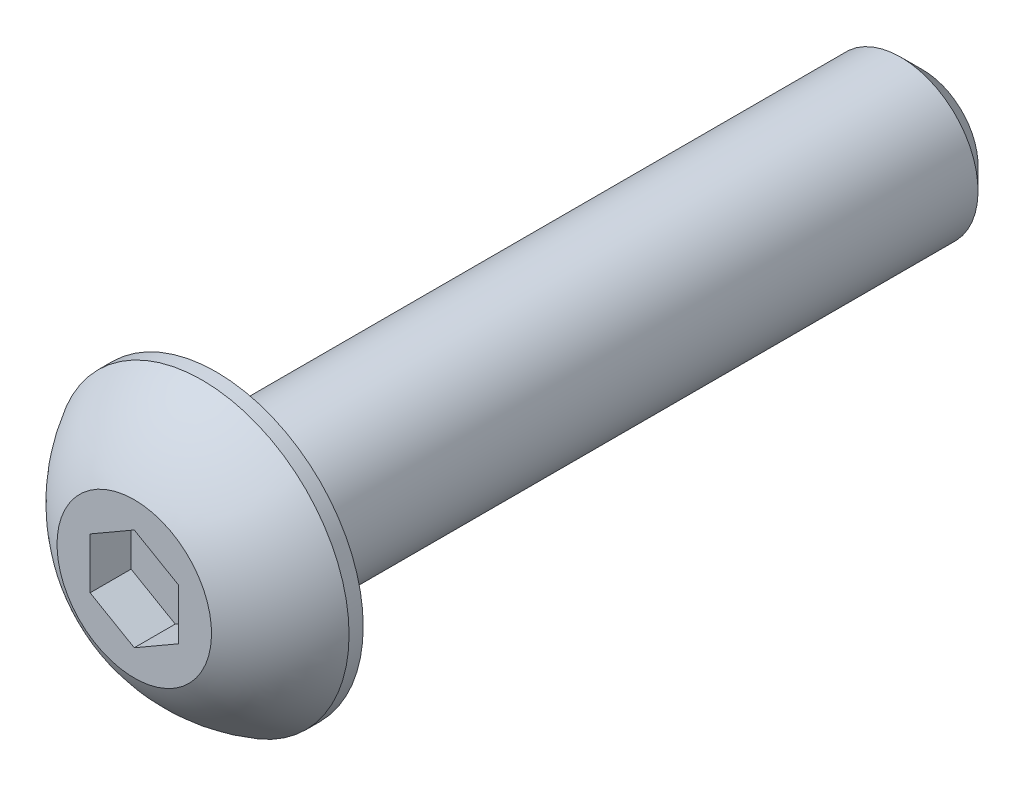
from build123d import *

# Parameters (mm, degrees)
SKETCH1_W          = 19.05
SKETCH1_H          = 2.0828
CHAMFER1_SIZE      = 0.5953125
SKETCH4_R          = 3.9624
EXTRUDE1_DEPTH     = 2.2098
CUT_EXTRUDE1_DEPTH = 1.1049


with BuildPart() as part:
    # Sketch1 → Revolve1 (revolve)
    with BuildSketch(Plane(origin=(0, 0, 0), x_dir=(0, 0, -1), z_dir=(1, 0, 0))):
        with Locations((9.525, 1.0414)):
            Rectangle(SKETCH1_W, SKETCH1_H)
    revolve(axis=Axis((0, 0, 0), (0, 0, 1)))

    # Chamfer1
    chamfer1_edges = [part.edges().sort_by_distance(p)[0] for p in [
        (0, -2.0828, -19.05),
    ]]
    chamfer(chamfer1_edges, length=CHAMFER1_SIZE)

    # Sketch4 → Extrude1 (add)
    with BuildSketch(Plane.XY):
        Circle(SKETCH4_R)
    extrude(amount=EXTRUDE1_DEPTH)

    # Sketch9 → Cut-Revolve3 (revolve, cut)
    with BuildSketch(Plane(origin=(0, 0, 0), x_dir=(0, 0, -1), z_dir=(1, 0, 0))):
        with BuildLine():
            Line((0, 3.9624), (-0.381, 3.9624))
            ThreePointArc((-0.381, 3.9624), (-1.434442989, 3.157885071), (-2.2098, 2.0828))
            Line((-2.2098, 2.0828), (-2.5908, 2.0828))
            Line((-2.5908, 2.0828), (-2.5908, 4.3434))
            Line((-2.5908, 4.3434), (0, 4.3434))
            Line((0, 4.3434), (0, 3.9624))
        make_face()
    revolve(axis=Axis((0, 0, 0), (0, 0, 1)), mode=Mode.SUBTRACT)

    # Sketch6 → Cut-Extrude1 (cut)
    with BuildSketch(Plane.XY.offset(2.2098)):
        Polygon((0, -1.374815329), (1.190625, -0.687407664), (1.190625, 0.687407664), (0, 1.374815329), (-1.190625, 0.687407664), (-1.190625, -0.687407664), align=None)
    extrude(amount=-CUT_EXTRUDE1_DEPTH, mode=Mode.SUBTRACT)


solid = part.part
